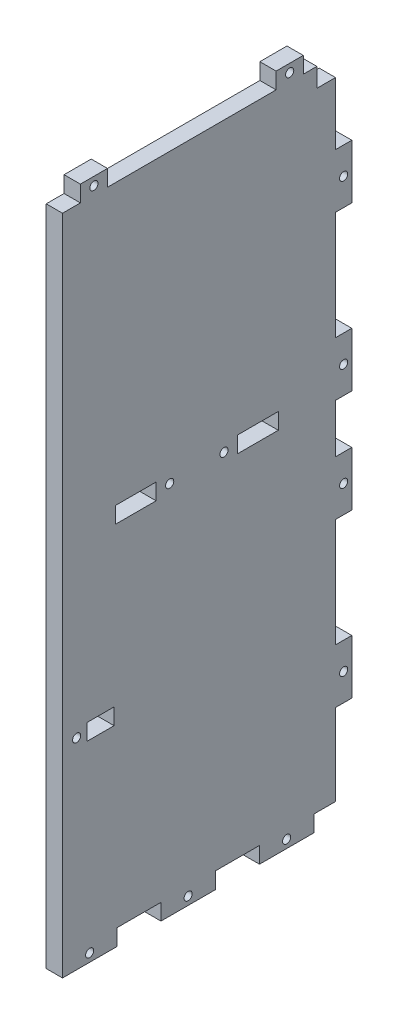
from build123d import *

# Parameters (mm, degrees)
ESQUISSE1_W             = 100.58
ESQUISSE1_H             = 238
ESQUISSE1_W_2           = 10
ESQUISSE1_H_2           = 6
ESQUISSE1_W_3           = 15
BOSS_EXTRU_1_DEPTH      = 6
ESQUISSE3_W             = 20
ESQUISSE3_H             = 6
ESQUISSE3_W_2           = 6
ESQUISSE3_H_2           = 20
ESQUISSE3_W_3           = 10
BOSS_EXTRU_5_DEPTH      = 6
ESQUISSE7_W             = 6.88
ESQUISSE7_H             = 7
ENL_V_MAT_EXTRU_3_DEPTH = 6
ESQUISSE8_R             = 1.5
ENL_V_MAT_EXTRU_4_DEPTH = 6


with BuildPart() as part:
    # Esquisse1 → Boss.-Extru.1 (new body)
    with BuildSketch(Plane(origin=(0, 0, 0), x_dir=(0, 0, -1), z_dir=(1, 0, 0))):
        Rectangle(ESQUISSE1_W, ESQUISSE1_H)
        with Locations((-36.29, -51)):
            Rectangle(ESQUISSE1_W_2, ESQUISSE1_H_2, mode=Mode.SUBTRACT)
        with Locations((-23.295, 13)):
            Rectangle(ESQUISSE1_W_3, ESQUISSE1_H_2, mode=Mode.SUBTRACT)
        with Locations((21.705, 13)):
            Rectangle(ESQUISSE1_W_3, ESQUISSE1_H_2, mode=Mode.SUBTRACT)
    extrude(amount=BOSS_EXTRU_1_DEPTH)

    # Esquisse3 → Boss.-Extru.5 (add)
    with BuildSketch(Plane(origin=(6, 0, 0), x_dir=(0, 0, -1), z_dir=(1, 0, 0))):
        with Locations((-40.29, -122)):
            Rectangle(ESQUISSE3_W, ESQUISSE3_H)
        with Locations((32.29, -122)):
            Rectangle(ESQUISSE3_W, ESQUISSE3_H)
        with Locations((53.29, 19)):
            Rectangle(ESQUISSE3_W_2, ESQUISSE3_H_2)
        with Locations((53.29, 79)):
            Rectangle(ESQUISSE3_W_2, ESQUISSE3_H_2)
        with Locations((53.29, -79)):
            Rectangle(ESQUISSE3_W_2, ESQUISSE3_H_2)
        with Locations((53.29, -19)):
            Rectangle(ESQUISSE3_W_2, ESQUISSE3_H_2)
        with Locations((-4, -122)):
            Rectangle(ESQUISSE3_W, ESQUISSE3_H)
        with Locations((33.41, 122)):
            Rectangle(ESQUISSE3_W_3, ESQUISSE3_H)
        with Locations((-38.71, 122)):
            Rectangle(ESQUISSE3_W_3, ESQUISSE3_H)
    extrude(amount=-BOSS_EXTRU_5_DEPTH)

    # Esquisse7 → Enlèv. mat.-Extru.3 (cut)
    with BuildSketch(Plane.ZY):
        with Locations((-46.85, 115.5)):
            Rectangle(ESQUISSE7_W, ESQUISSE7_H)
    extrude(amount=-ENL_V_MAT_EXTRU_3_DEPTH, mode=Mode.SUBTRACT)

    # Esquisse8 → Enlèv. mat.-Extru.4 (cut)
    with BuildSketch(Plane.ZY):
        with Locations((4, -122)):
            Circle(ESQUISSE8_R)
        with Locations((-9.205, 13)):
            Circle(ESQUISSE8_R)
        with Locations((10.795, 13)):
            Circle(ESQUISSE8_R)
        with Locations((45.08, -51)):
            Circle(ESQUISSE8_R)
        with Locations((38.71, 122)):
            Circle(ESQUISSE8_R)
        with Locations((-33.41, 122)):
            Circle(ESQUISSE8_R)
        with Locations((40.29, -122)):
            Circle(ESQUISSE8_R)
        with Locations((-53.29, 79)):
            Circle(ESQUISSE8_R)
        with Locations((-32.29, -122)):
            Circle(ESQUISSE8_R)
        with Locations((-53.29, 19)):
            Circle(ESQUISSE8_R)
        with Locations((-53.29, -79)):
            Circle(ESQUISSE8_R)
        with Locations((-53.29, -19)):
            Circle(ESQUISSE8_R)
    extrude(amount=-ENL_V_MAT_EXTRU_4_DEPTH, mode=Mode.SUBTRACT)


solid = part.part
